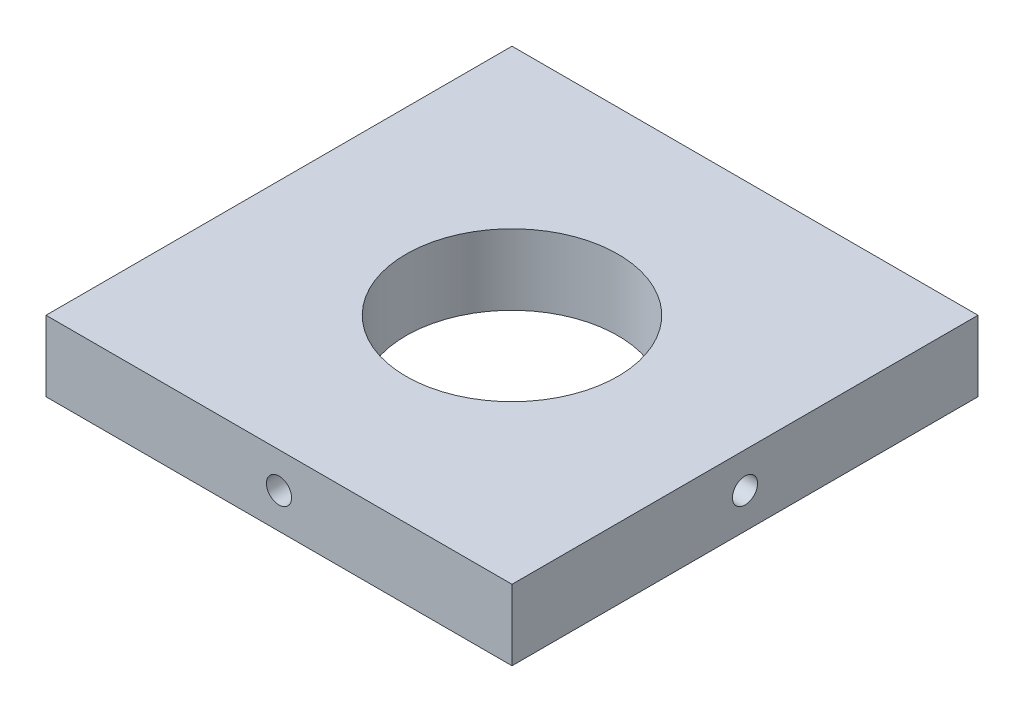
from build123d import *

# Parameters (mm, degrees)
SKETCH1_W                 = 33
SKETCH1_H                 = 33
SKETCH1_R                 = 7.5
BOSS_EXTRUDE1_DEPTH       = 5
F_2_56_TAPPED_HOLE4_D     = 1.778
F_2_56_TAPPED_HOLE4_DEPTH = 7.46583491
F_2_56_TAPPED_HOLE4_TIP   = 0.53416509
F_2_56_TAPPED_HOLE5_D     = 1.778
F_2_56_TAPPED_HOLE5_DEPTH = 7.46583491
F_2_56_TAPPED_HOLE5_TIP   = 0.53416509
F_2_56_TAPPED_HOLE6_D     = 1.778
F_2_56_TAPPED_HOLE6_DEPTH = 7.46583491
F_2_56_TAPPED_HOLE6_TIP   = 0.53416509
F_2_56_TAPPED_HOLE7_D     = 1.778
F_2_56_TAPPED_HOLE7_DEPTH = 7.46583491
F_2_56_TAPPED_HOLE7_TIP   = 0.53416509


with BuildPart() as part:
    # Sketch1 → Boss-Extrude1 (new body)
    with BuildSketch(Plane(origin=(0, 0, 0), x_dir=(1, 0, 0), z_dir=(0, 1, 0))):
        Rectangle(SKETCH1_W, SKETCH1_H)
        Circle(SKETCH1_R, mode=Mode.SUBTRACT)
    extrude(amount=BOSS_EXTRUDE1_DEPTH)

    # #2-56 Tapped Hole4
    with Locations(Plane.XY.offset(16.5)):
        with Locations((0, 2.5)):
            Hole(F_2_56_TAPPED_HOLE4_D / 2, depth=F_2_56_TAPPED_HOLE4_DEPTH)
            with Locations((0, 0, -(F_2_56_TAPPED_HOLE4_DEPTH + F_2_56_TAPPED_HOLE4_TIP / 2))):  # 118° drill point
                Cone(0, F_2_56_TAPPED_HOLE4_D / 2, F_2_56_TAPPED_HOLE4_TIP, mode=Mode.SUBTRACT)

    # #2-56 Tapped Hole5
    with Locations(Plane(origin=(0, 0, -16.5), x_dir=(-1, 0, 0), z_dir=(0, 0, -1))):
        with Locations((0, 2.5)):
            Hole(F_2_56_TAPPED_HOLE5_D / 2, depth=F_2_56_TAPPED_HOLE5_DEPTH)
            with Locations((0, 0, -(F_2_56_TAPPED_HOLE5_DEPTH + F_2_56_TAPPED_HOLE5_TIP / 2))):  # 118° drill point
                Cone(0, F_2_56_TAPPED_HOLE5_D / 2, F_2_56_TAPPED_HOLE5_TIP, mode=Mode.SUBTRACT)

    # #2-56 Tapped Hole6
    with Locations(Plane(origin=(16.5, 0, 0), x_dir=(0, 0, -1), z_dir=(1, 0, 0))):
        with Locations((0, 2.5)):
            Hole(F_2_56_TAPPED_HOLE6_D / 2, depth=F_2_56_TAPPED_HOLE6_DEPTH)
            with Locations((0, 0, -(F_2_56_TAPPED_HOLE6_DEPTH + F_2_56_TAPPED_HOLE6_TIP / 2))):  # 118° drill point
                Cone(0, F_2_56_TAPPED_HOLE6_D / 2, F_2_56_TAPPED_HOLE6_TIP, mode=Mode.SUBTRACT)

    # #2-56 Tapped Hole7
    with Locations(Plane.ZY.offset(16.5)):
        with Locations((0, 2.5)):
            Hole(F_2_56_TAPPED_HOLE7_D / 2, depth=F_2_56_TAPPED_HOLE7_DEPTH)
            with Locations((0, 0, -(F_2_56_TAPPED_HOLE7_DEPTH + F_2_56_TAPPED_HOLE7_TIP / 2))):  # 118° drill point
                Cone(0, F_2_56_TAPPED_HOLE7_D / 2, F_2_56_TAPPED_HOLE7_TIP, mode=Mode.SUBTRACT)


solid = part.part
